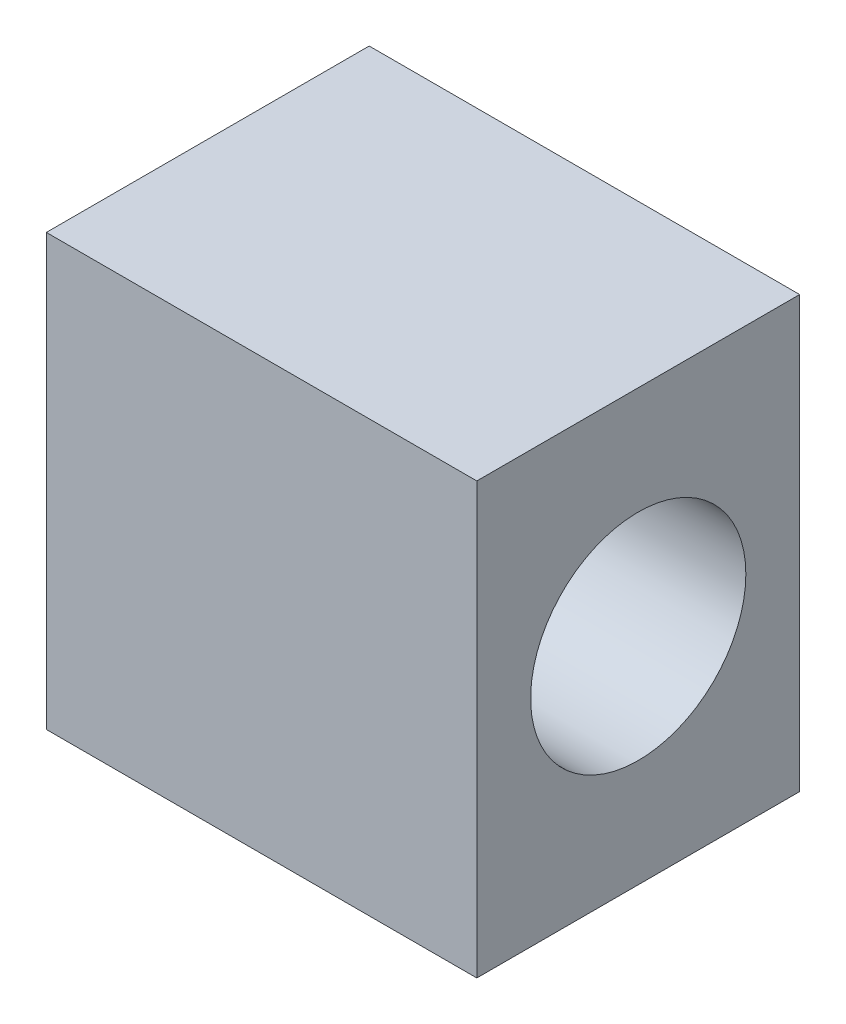
from build123d import *

# Parameters (mm, degrees)
SKETCH3_W           = 20
SKETCH3_H           = 15
BOSS_EXTRUDE1_DEPTH = 20
SKETCH5_R           = 5
CUT_EXTRUDE1_DEPTH  = 10
SKETCH6_R           = 5
CUT_EXTRUDE2_DEPTH  = 4


with BuildPart() as part:
    # Sketch3 → Boss-Extrude1 (new body)
    with BuildSketch(Plane(origin=(0, 0, 0), x_dir=(1, 0, 0), z_dir=(0, 1, 0))):
        Rectangle(SKETCH3_W, SKETCH3_H)
    extrude(amount=BOSS_EXTRUDE1_DEPTH)

    # Sketch5 → Cut-Extrude1 (cut)
    with BuildSketch(Plane(origin=(10, 0, 0), x_dir=(0, 0, -1), z_dir=(1, 0, 0))):
        with Locations((0, 10)):
            Circle(SKETCH5_R)
    extrude(amount=-CUT_EXTRUDE1_DEPTH, mode=Mode.SUBTRACT)

    # Sketch6 → Cut-Extrude2 (cut)
    with BuildSketch(Plane.ZY.offset(10)):
        with Locations((0, 10)):
            Circle(SKETCH6_R)
    extrude(amount=-CUT_EXTRUDE2_DEPTH, mode=Mode.SUBTRACT)


solid = part.part
